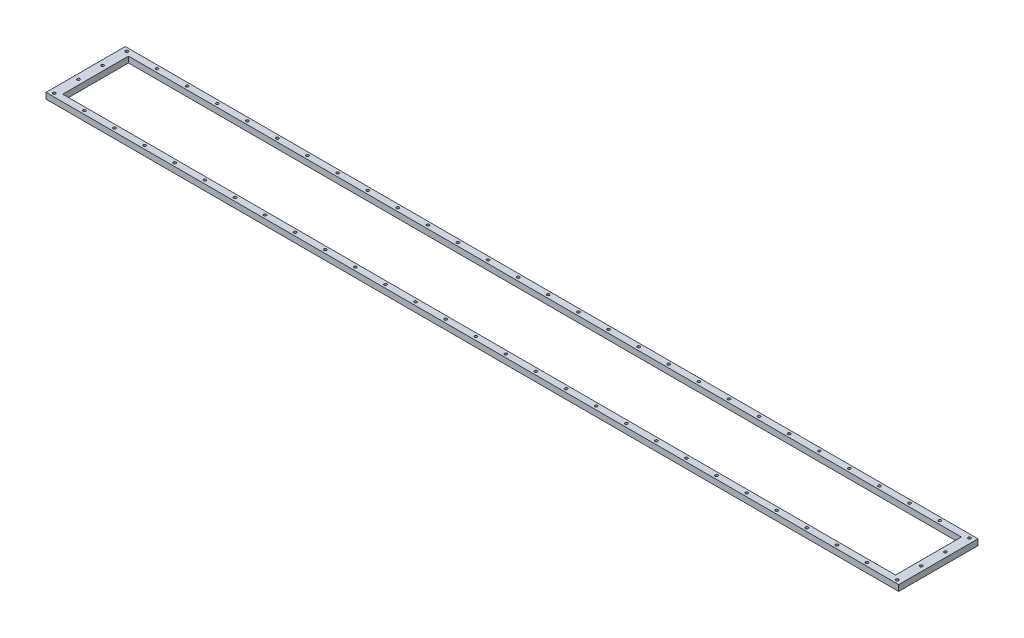
from build123d import *

# Parameters (mm, degrees)
SKETCH2_W                = 1075
SKETCH2_H                = 100
SKETCH2_W_2              = 1050
SKETCH2_H_2              = 83
BOSS_EXTRUDE1_DEPTH      = 7.5
CUT_EXTRUDE1_START       = -8.5
SKETCH3_R                = 1.7
CUT_EXTRUDE1_DEPTH       = 9.5
LPATTERN1_COUNT          = 4
LPATTERN1_PITCH          = 30.425
LPATTERN2_COUNT          = 29
LPATTERN2_PITCH          = 37.95
MIRROR1_START            = -8.5
MIRROR1_COPY_1_SKETCH_R  = 1.7
MIRROR1_COPY_1_DEPTH     = 9.5
MIRROR1_COPY_2_SKETCH_R  = 1.7
MIRROR1_COPY_2_DEPTH     = 9.5
MIRROR1_COPY_3_SKETCH_R  = 1.7
MIRROR1_COPY_3_DEPTH     = 9.5
MIRROR1_COPY_4_SKETCH_R  = 1.7
MIRROR1_COPY_4_DEPTH     = 9.5
MIRROR1_COPY_5_SKETCH_R  = 1.7
MIRROR1_COPY_5_DEPTH     = 9.5
MIRROR1_COPY_6_SKETCH_R  = 1.7
MIRROR1_COPY_6_DEPTH     = 9.5
MIRROR1_COPY_7_SKETCH_R  = 1.7
MIRROR1_COPY_7_DEPTH     = 9.5
MIRROR1_COPY_8_SKETCH_R  = 1.7
MIRROR1_COPY_8_DEPTH     = 9.5
MIRROR1_COPY_9_SKETCH_R  = 1.7
MIRROR1_COPY_9_DEPTH     = 9.5
MIRROR1_COPY_10_SKETCH_R = 1.7
MIRROR1_COPY_10_DEPTH    = 9.5
MIRROR1_COPY_11_SKETCH_R = 1.7
MIRROR1_COPY_11_DEPTH    = 9.5
MIRROR1_COPY_12_SKETCH_R = 1.7
MIRROR1_COPY_12_DEPTH    = 9.5
MIRROR1_COPY_13_SKETCH_R = 1.7
MIRROR1_COPY_13_DEPTH    = 9.5
MIRROR1_COPY_14_SKETCH_R = 1.7
MIRROR1_COPY_14_DEPTH    = 9.5
MIRROR1_COPY_15_SKETCH_R = 1.7
MIRROR1_COPY_15_DEPTH    = 9.5
MIRROR1_COPY_16_SKETCH_R = 1.7
MIRROR1_COPY_16_DEPTH    = 9.5
MIRROR1_COPY_17_SKETCH_R = 1.7
MIRROR1_COPY_17_DEPTH    = 9.5
MIRROR1_COPY_18_SKETCH_R = 1.7
MIRROR1_COPY_18_DEPTH    = 9.5
MIRROR1_COPY_19_SKETCH_R = 1.7
MIRROR1_COPY_19_DEPTH    = 9.5
MIRROR1_COPY_20_SKETCH_R = 1.7
MIRROR1_COPY_20_DEPTH    = 9.5
MIRROR1_COPY_21_SKETCH_R = 1.7
MIRROR1_COPY_21_DEPTH    = 9.5
MIRROR1_COPY_22_SKETCH_R = 1.7
MIRROR1_COPY_22_DEPTH    = 9.5
MIRROR1_COPY_23_SKETCH_R = 1.7
MIRROR1_COPY_23_DEPTH    = 9.5
MIRROR1_COPY_24_SKETCH_R = 1.7
MIRROR1_COPY_24_DEPTH    = 9.5
MIRROR1_COPY_25_SKETCH_R = 1.7
MIRROR1_COPY_25_DEPTH    = 9.5
MIRROR1_COPY_26_SKETCH_R = 1.7
MIRROR1_COPY_26_DEPTH    = 9.5
MIRROR1_COPY_27_SKETCH_R = 1.7
MIRROR1_COPY_27_DEPTH    = 9.5
MIRROR1_COPY_28_SKETCH_R = 1.7
MIRROR1_COPY_28_DEPTH    = 9.5
MIRROR2_START            = -8.5
MIRROR2_COPY_1_SKETCH_R  = 1.7
MIRROR2_COPY_1_DEPTH     = 9.5
MIRROR2_COPY_2_SKETCH_R  = 1.7
MIRROR2_COPY_2_DEPTH     = 9.5
MIRROR2_COPY_3_SKETCH_R  = 1.7
MIRROR2_COPY_3_DEPTH     = 9.5


with BuildPart() as part:
    # Sketch2 → Boss-Extrude1 (new body)
    with BuildSketch(Plane(origin=(0, 0, 0), x_dir=(1, 0, 0), z_dir=(0, 1, 0))):
        Rectangle(SKETCH2_W, SKETCH2_H)
        Rectangle(SKETCH2_W_2, SKETCH2_H_2, mode=Mode.SUBTRACT)
    extrude(amount=BOSS_EXTRUDE1_DEPTH)

    # Sketch3 → Cut-Extrude1 (cut)
    with BuildSketch(Plane.XZ.offset(CUT_EXTRUDE1_START)):
        with Locations((-531.25, 45.75)):
            Circle(SKETCH3_R)
    cut_extrude1 = extrude(amount=CUT_EXTRUDE1_DEPTH, mode=Mode.SUBTRACT)

    # LPattern1: Cut-Extrude1 ×4
    with Locations(*[(0, 0, -i * LPATTERN1_PITCH) for i in range(1, LPATTERN1_COUNT)]):
        add(cut_extrude1, mode=Mode.SUBTRACT)

    # LPattern2: Cut-Extrude1 ×29
    with Locations(*[(i * LPATTERN2_PITCH, 0, 0) for i in range(1, LPATTERN2_COUNT)]):
        add(cut_extrude1, mode=Mode.SUBTRACT)

    # Mirror1: Cut-Extrude1 across plane
    add(cut_extrude1.mirror(Plane.XY), mode=Mode.SUBTRACT)

    # Mirror1 copy 1 sketch → Mirror1 copy 1 (cut)
    with BuildSketch(Plane(origin=(37.95, 0, 0), x_dir=(1, 0, 0), z_dir=(0, -1, 0)).offset(MIRROR1_START)):
        with Locations((-531.25, -45.75)):
            Circle(MIRROR1_COPY_1_SKETCH_R)
    extrude(amount=MIRROR1_COPY_1_DEPTH, mode=Mode.SUBTRACT)

    # Mirror1 copy 2 sketch → Mirror1 copy 2 (cut)
    with BuildSketch(Plane(origin=(75.9, 0, 0), x_dir=(1, 0, 0), z_dir=(0, -1, 0)).offset(MIRROR1_START)):
        with Locations((-531.25, -45.75)):
            Circle(MIRROR1_COPY_2_SKETCH_R)
    extrude(amount=MIRROR1_COPY_2_DEPTH, mode=Mode.SUBTRACT)

    # Mirror1 copy 3 sketch → Mirror1 copy 3 (cut)
    with BuildSketch(Plane(origin=(113.85, 0, 0), x_dir=(1, 0, 0), z_dir=(0, -1, 0)).offset(MIRROR1_START)):
        with Locations((-531.25, -45.75)):
            Circle(MIRROR1_COPY_3_SKETCH_R)
    extrude(amount=MIRROR1_COPY_3_DEPTH, mode=Mode.SUBTRACT)

    # Mirror1 copy 4 sketch → Mirror1 copy 4 (cut)
    with BuildSketch(Plane(origin=(151.8, 0, 0), x_dir=(1, 0, 0), z_dir=(0, -1, 0)).offset(MIRROR1_START)):
        with Locations((-531.25, -45.75)):
            Circle(MIRROR1_COPY_4_SKETCH_R)
    extrude(amount=MIRROR1_COPY_4_DEPTH, mode=Mode.SUBTRACT)

    # Mirror1 copy 5 sketch → Mirror1 copy 5 (cut)
    with BuildSketch(Plane(origin=(189.75, 0, 0), x_dir=(1, 0, 0), z_dir=(0, -1, 0)).offset(MIRROR1_START)):
        with Locations((-531.25, -45.75)):
            Circle(MIRROR1_COPY_5_SKETCH_R)
    extrude(amount=MIRROR1_COPY_5_DEPTH, mode=Mode.SUBTRACT)

    # Mirror1 copy 6 sketch → Mirror1 copy 6 (cut)
    with BuildSketch(Plane(origin=(227.7, 0, 0), x_dir=(1, 0, 0), z_dir=(0, -1, 0)).offset(MIRROR1_START)):
        with Locations((-531.25, -45.75)):
            Circle(MIRROR1_COPY_6_SKETCH_R)
    extrude(amount=MIRROR1_COPY_6_DEPTH, mode=Mode.SUBTRACT)

    # Mirror1 copy 7 sketch → Mirror1 copy 7 (cut)
    with BuildSketch(Plane(origin=(265.65, 0, 0), x_dir=(1, 0, 0), z_dir=(0, -1, 0)).offset(MIRROR1_START)):
        with Locations((-531.25, -45.75)):
            Circle(MIRROR1_COPY_7_SKETCH_R)
    extrude(amount=MIRROR1_COPY_7_DEPTH, mode=Mode.SUBTRACT)

    # Mirror1 copy 8 sketch → Mirror1 copy 8 (cut)
    with BuildSketch(Plane(origin=(303.6, 0, 0), x_dir=(1, 0, 0), z_dir=(0, -1, 0)).offset(MIRROR1_START)):
        with Locations((-531.25, -45.75)):
            Circle(MIRROR1_COPY_8_SKETCH_R)
    extrude(amount=MIRROR1_COPY_8_DEPTH, mode=Mode.SUBTRACT)

    # Mirror1 copy 9 sketch → Mirror1 copy 9 (cut)
    with BuildSketch(Plane(origin=(341.55, 0, 0), x_dir=(1, 0, 0), z_dir=(0, -1, 0)).offset(MIRROR1_START)):
        with Locations((-531.25, -45.75)):
            Circle(MIRROR1_COPY_9_SKETCH_R)
    extrude(amount=MIRROR1_COPY_9_DEPTH, mode=Mode.SUBTRACT)

    # Mirror1 copy 10 sketch → Mirror1 copy 10 (cut)
    with BuildSketch(Plane(origin=(379.5, 0, 0), x_dir=(1, 0, 0), z_dir=(0, -1, 0)).offset(MIRROR1_START)):
        with Locations((-531.25, -45.75)):
            Circle(MIRROR1_COPY_10_SKETCH_R)
    extrude(amount=MIRROR1_COPY_10_DEPTH, mode=Mode.SUBTRACT)

    # Mirror1 copy 11 sketch → Mirror1 copy 11 (cut)
    with BuildSketch(Plane(origin=(417.45, 0, 0), x_dir=(1, 0, 0), z_dir=(0, -1, 0)).offset(MIRROR1_START)):
        with Locations((-531.25, -45.75)):
            Circle(MIRROR1_COPY_11_SKETCH_R)
    extrude(amount=MIRROR1_COPY_11_DEPTH, mode=Mode.SUBTRACT)

    # Mirror1 copy 12 sketch → Mirror1 copy 12 (cut)
    with BuildSketch(Plane(origin=(455.4, 0, 0), x_dir=(1, 0, 0), z_dir=(0, -1, 0)).offset(MIRROR1_START)):
        with Locations((-531.25, -45.75)):
            Circle(MIRROR1_COPY_12_SKETCH_R)
    extrude(amount=MIRROR1_COPY_12_DEPTH, mode=Mode.SUBTRACT)

    # Mirror1 copy 13 sketch → Mirror1 copy 13 (cut)
    with BuildSketch(Plane(origin=(493.35, 0, 0), x_dir=(1, 0, 0), z_dir=(0, -1, 0)).offset(MIRROR1_START)):
        with Locations((-531.25, -45.75)):
            Circle(MIRROR1_COPY_13_SKETCH_R)
    extrude(amount=MIRROR1_COPY_13_DEPTH, mode=Mode.SUBTRACT)

    # Mirror1 copy 14 sketch → Mirror1 copy 14 (cut)
    with BuildSketch(Plane(origin=(531.3, 0, 0), x_dir=(1, 0, 0), z_dir=(0, -1, 0)).offset(MIRROR1_START)):
        with Locations((-531.25, -45.75)):
            Circle(MIRROR1_COPY_14_SKETCH_R)
    extrude(amount=MIRROR1_COPY_14_DEPTH, mode=Mode.SUBTRACT)

    # Mirror1 copy 15 sketch → Mirror1 copy 15 (cut)
    with BuildSketch(Plane(origin=(569.25, 0, 0), x_dir=(1, 0, 0), z_dir=(0, -1, 0)).offset(MIRROR1_START)):
        with Locations((-531.25, -45.75)):
            Circle(MIRROR1_COPY_15_SKETCH_R)
    extrude(amount=MIRROR1_COPY_15_DEPTH, mode=Mode.SUBTRACT)

    # Mirror1 copy 16 sketch → Mirror1 copy 16 (cut)
    with BuildSketch(Plane(origin=(607.2, 0, 0), x_dir=(1, 0, 0), z_dir=(0, -1, 0)).offset(MIRROR1_START)):
        with Locations((-531.25, -45.75)):
            Circle(MIRROR1_COPY_16_SKETCH_R)
    extrude(amount=MIRROR1_COPY_16_DEPTH, mode=Mode.SUBTRACT)

    # Mirror1 copy 17 sketch → Mirror1 copy 17 (cut)
    with BuildSketch(Plane(origin=(645.15, 0, 0), x_dir=(1, 0, 0), z_dir=(0, -1, 0)).offset(MIRROR1_START)):
        with Locations((-531.25, -45.75)):
            Circle(MIRROR1_COPY_17_SKETCH_R)
    extrude(amount=MIRROR1_COPY_17_DEPTH, mode=Mode.SUBTRACT)

    # Mirror1 copy 18 sketch → Mirror1 copy 18 (cut)
    with BuildSketch(Plane(origin=(683.1, 0, 0), x_dir=(1, 0, 0), z_dir=(0, -1, 0)).offset(MIRROR1_START)):
        with Locations((-531.25, -45.75)):
            Circle(MIRROR1_COPY_18_SKETCH_R)
    extrude(amount=MIRROR1_COPY_18_DEPTH, mode=Mode.SUBTRACT)

    # Mirror1 copy 19 sketch → Mirror1 copy 19 (cut)
    with BuildSketch(Plane(origin=(721.05, 0, 0), x_dir=(1, 0, 0), z_dir=(0, -1, 0)).offset(MIRROR1_START)):
        with Locations((-531.25, -45.75)):
            Circle(MIRROR1_COPY_19_SKETCH_R)
    extrude(amount=MIRROR1_COPY_19_DEPTH, mode=Mode.SUBTRACT)

    # Mirror1 copy 20 sketch → Mirror1 copy 20 (cut)
    with BuildSketch(Plane(origin=(759, 0, 0), x_dir=(1, 0, 0), z_dir=(0, -1, 0)).offset(MIRROR1_START)):
        with Locations((-531.25, -45.75)):
            Circle(MIRROR1_COPY_20_SKETCH_R)
    extrude(amount=MIRROR1_COPY_20_DEPTH, mode=Mode.SUBTRACT)

    # Mirror1 copy 21 sketch → Mirror1 copy 21 (cut)
    with BuildSketch(Plane(origin=(796.95, 0, 0), x_dir=(1, 0, 0), z_dir=(0, -1, 0)).offset(MIRROR1_START)):
        with Locations((-531.25, -45.75)):
            Circle(MIRROR1_COPY_21_SKETCH_R)
    extrude(amount=MIRROR1_COPY_21_DEPTH, mode=Mode.SUBTRACT)

    # Mirror1 copy 22 sketch → Mirror1 copy 22 (cut)
    with BuildSketch(Plane(origin=(834.9, 0, 0), x_dir=(1, 0, 0), z_dir=(0, -1, 0)).offset(MIRROR1_START)):
        with Locations((-531.25, -45.75)):
            Circle(MIRROR1_COPY_22_SKETCH_R)
    extrude(amount=MIRROR1_COPY_22_DEPTH, mode=Mode.SUBTRACT)

    # Mirror1 copy 23 sketch → Mirror1 copy 23 (cut)
    with BuildSketch(Plane(origin=(872.85, 0, 0), x_dir=(1, 0, 0), z_dir=(0, -1, 0)).offset(MIRROR1_START)):
        with Locations((-531.25, -45.75)):
            Circle(MIRROR1_COPY_23_SKETCH_R)
    extrude(amount=MIRROR1_COPY_23_DEPTH, mode=Mode.SUBTRACT)

    # Mirror1 copy 24 sketch → Mirror1 copy 24 (cut)
    with BuildSketch(Plane(origin=(910.8, 0, 0), x_dir=(1, 0, 0), z_dir=(0, -1, 0)).offset(MIRROR1_START)):
        with Locations((-531.25, -45.75)):
            Circle(MIRROR1_COPY_24_SKETCH_R)
    extrude(amount=MIRROR1_COPY_24_DEPTH, mode=Mode.SUBTRACT)

    # Mirror1 copy 25 sketch → Mirror1 copy 25 (cut)
    with BuildSketch(Plane(origin=(948.75, 0, 0), x_dir=(1, 0, 0), z_dir=(0, -1, 0)).offset(MIRROR1_START)):
        with Locations((-531.25, -45.75)):
            Circle(MIRROR1_COPY_25_SKETCH_R)
    extrude(amount=MIRROR1_COPY_25_DEPTH, mode=Mode.SUBTRACT)

    # Mirror1 copy 26 sketch → Mirror1 copy 26 (cut)
    with BuildSketch(Plane(origin=(986.7, 0, 0), x_dir=(1, 0, 0), z_dir=(0, -1, 0)).offset(MIRROR1_START)):
        with Locations((-531.25, -45.75)):
            Circle(MIRROR1_COPY_26_SKETCH_R)
    extrude(amount=MIRROR1_COPY_26_DEPTH, mode=Mode.SUBTRACT)

    # Mirror1 copy 27 sketch → Mirror1 copy 27 (cut)
    with BuildSketch(Plane(origin=(1024.65, 0, 0), x_dir=(1, 0, 0), z_dir=(0, -1, 0)).offset(MIRROR1_START)):
        with Locations((-531.25, -45.75)):
            Circle(MIRROR1_COPY_27_SKETCH_R)
    extrude(amount=MIRROR1_COPY_27_DEPTH, mode=Mode.SUBTRACT)

    # Mirror1 copy 28 sketch → Mirror1 copy 28 (cut)
    with BuildSketch(Plane(origin=(1062.6, 0, 0), x_dir=(1, 0, 0), z_dir=(0, -1, 0)).offset(MIRROR1_START)):
        with Locations((-531.25, -45.75)):
            Circle(MIRROR1_COPY_28_SKETCH_R)
    extrude(amount=MIRROR1_COPY_28_DEPTH, mode=Mode.SUBTRACT)

    # Mirror2: Cut-Extrude1 across plane
    add(cut_extrude1.mirror(Plane(origin=(0, 0, 0), x_dir=(0, 0, 1), z_dir=(1, 0, 0))), mode=Mode.SUBTRACT)

    # Mirror2 copy 1 sketch → Mirror2 copy 1 (cut)
    with BuildSketch(Plane(origin=(0, 0, -30.425), x_dir=(-1, 0, 0), z_dir=(0, -1, 0)).offset(MIRROR2_START)):
        with Locations((-531.25, -45.75)):
            Circle(MIRROR2_COPY_1_SKETCH_R)
    extrude(amount=MIRROR2_COPY_1_DEPTH, mode=Mode.SUBTRACT)

    # Mirror2 copy 2 sketch → Mirror2 copy 2 (cut)
    with BuildSketch(Plane(origin=(0, 0, -60.85), x_dir=(-1, 0, 0), z_dir=(0, -1, 0)).offset(MIRROR2_START)):
        with Locations((-531.25, -45.75)):
            Circle(MIRROR2_COPY_2_SKETCH_R)
    extrude(amount=MIRROR2_COPY_2_DEPTH, mode=Mode.SUBTRACT)

    # Mirror2 copy 3 sketch → Mirror2 copy 3 (cut)
    with BuildSketch(Plane(origin=(0, 0, -91.275), x_dir=(-1, 0, 0), z_dir=(0, -1, 0)).offset(MIRROR2_START)):
        with Locations((-531.25, -45.75)):
            Circle(MIRROR2_COPY_3_SKETCH_R)
    extrude(amount=MIRROR2_COPY_3_DEPTH, mode=Mode.SUBTRACT)


solid = part.part
